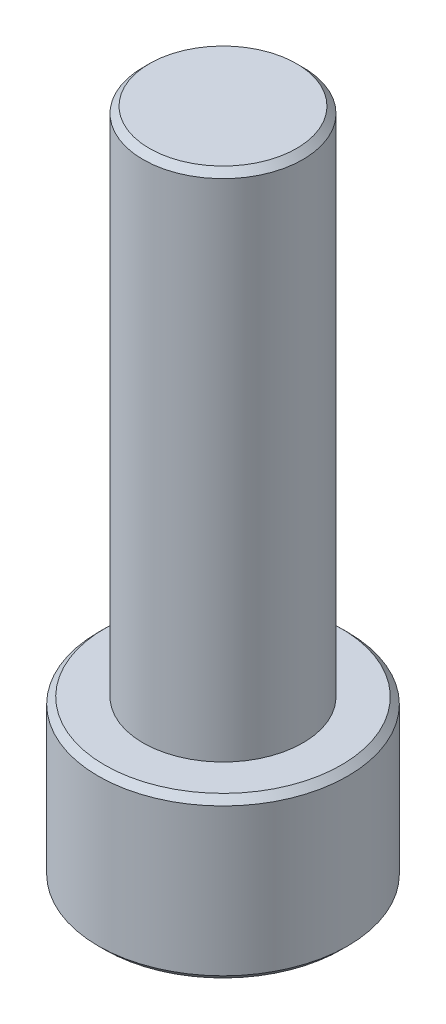
from build123d import *

# Parameters (mm, degrees)
SKETCH_1_R          = 1.95
EXTRUDE_1_DEPTH     = 2.5
SKETCH_1_3_R        = 1.25
EXTRUDE_2_DEPTH     = 8
CUT_EXTRUDE_START   = -1.25
CUT_EXTRUDE_1_DEPTH = 8.211973765
CHAMFER_1_SIZE      = 0.1


with BuildPart() as part:
    # Эскиз1 → Бобышка-Вытянуть1 (new body)
    with BuildSketch(Plane(origin=(0, 0, 0), x_dir=(1, 0, 0), z_dir=(0, 1, 0))):
        Circle(SKETCH_1_R)
    extrude(amount=-EXTRUDE_1_DEPTH)

    # Эскиз1<3> → Бобышка-Вытянуть2 (add)
    with BuildSketch(Plane(origin=(0, 0, 0), x_dir=(1, 0, 0), z_dir=(0, 1, 0))):
        Circle(SKETCH_1_3_R)
    extrude(amount=EXTRUDE_2_DEPTH)

    # Эскиз1<6> → Вырез-Вытянуть1 (cut, through all)
    with BuildSketch(Plane(origin=(0, 0, 0), x_dir=(1, 0, 0), z_dir=(0, 1, 0)).offset(CUT_EXTRUDE_START)):
        Polygon((0, 1.154700538), (-1, 0.577350269), (-1, -0.577350269), (0, -1.154700538), (1, -0.577350269), (1, 0.577350269), align=None)
    extrude(amount=-CUT_EXTRUDE_1_DEPTH, mode=Mode.SUBTRACT)

    # Фаска1
    chamfer_1_edges = [part.edges().sort_by_distance(p)[0] for p in [
        (-1.25, 8, 0),
        (-1.95, 0, 0),
        (-1.95, -2.5, 0),
    ]]
    chamfer(chamfer_1_edges, length=CHAMFER_1_SIZE)


solid = part.part
